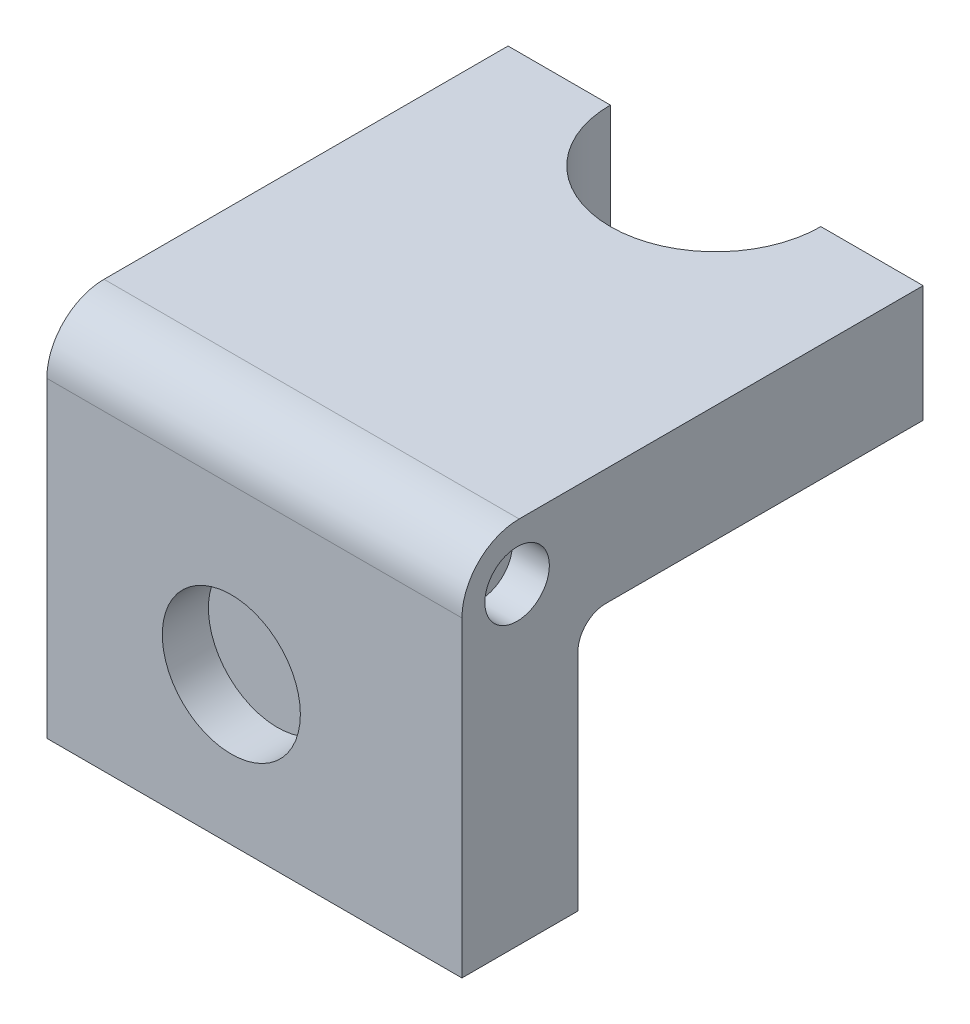
from build123d import *

# Parameters (mm, degrees)
SKETCH1_W           = 57.15
SKETCH1_H           = 50.8
BOSS_EXTRUDE1_DEPTH = 63.5
SKETCH2_R           = 9.506140486
CUT_EXTRUDE1_DEPTH  = 6.35
FILLET1_R           = 7.874
SKETCH3_W           = 47.524607072
SKETCH3_H           = 34.745914464
CUT_EXTRUDE2_DEPTH  = 57.15
FILLET2_R           = 3.81
SKETCH4_R           = 4.44219446
CUT_EXTRUDE3_DEPTH  = 5.08
CUT_EXTRUDE4_DEPTH  = 25.4


with BuildPart() as part:
    # Sketch1 → Boss-Extrude1 (new body)
    with BuildSketch(Plane.XY):
        with Locations((28.575, 25.4)):
            Rectangle(SKETCH1_W, SKETCH1_H)
    extrude(amount=BOSS_EXTRUDE1_DEPTH)

    # Sketch2 → Cut-Extrude1 (cut)
    with BuildSketch(Plane.XY.offset(63.5)):
        with Locations((25.4, 20.32)):
            Circle(SKETCH2_R)
    extrude(amount=-CUT_EXTRUDE1_DEPTH, mode=Mode.SUBTRACT)

    # Fillet1
    fillet1_edges = [part.edges().sort_by_distance(p)[0] for p in [
        (28.575, 50.8, 63.5),
    ]]
    fillet(fillet1_edges, radius=FILLET1_R)

    # Sketch3 → Cut-Extrude2 (cut)
    with BuildSketch(Plane(origin=(57.15, 0, 0), x_dir=(0, 0, -1), z_dir=(1, 0, 0))):
        with Locations((-23.762303536, 17.372957232)):
            Rectangle(SKETCH3_W, SKETCH3_H)
    extrude(amount=-CUT_EXTRUDE2_DEPTH, mode=Mode.SUBTRACT)

    # Fillet2
    fillet2_edges = [part.edges().sort_by_distance(p)[0] for p in [
        (28.575, 34.745914464, 47.524607072),
    ]]
    fillet(fillet2_edges, radius=FILLET2_R)

    # Sketch4 → Cut-Extrude3 (cut)
    with BuildSketch(Plane(origin=(57.15, 0, 0), x_dir=(0, 0, -1), z_dir=(1, 0, 0))):
        with Locations((-55.906607072, 43.18)):
            Circle(SKETCH4_R)
    extrude(amount=-CUT_EXTRUDE3_DEPTH, mode=Mode.SUBTRACT)

    # Sketch5 → Cut-Extrude4 (cut)
    with BuildSketch(Plane(origin=(0, 50.8, 0), x_dir=(1, 0, 0), z_dir=(0, 1, 0))):
        with BuildLine():
            Line((14.081947764, 0), (43.068052236, 0))
            ThreePointArc((43.068052236, 0), (28.575, -14.493052236), (14.081947764, 0))
        make_face()
    extrude(amount=-CUT_EXTRUDE4_DEPTH, mode=Mode.SUBTRACT)


solid = part.part
